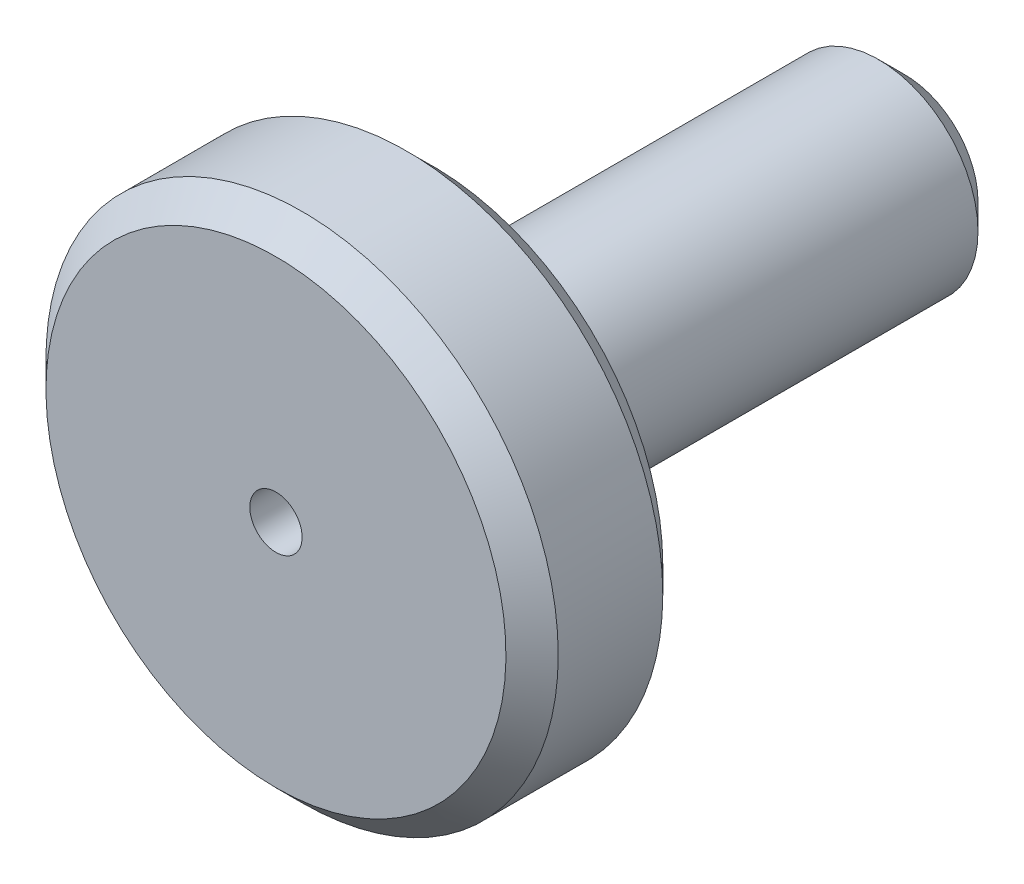
from build123d import *

# Parameters (mm, degrees)
SKETCH1_R           = 4.9
SKETCH1_R_2         = 1.9
BOSS_EXTRUDE1_DEPTH = 3
SKETCH1_4_R         = 1.9
BOSS_EXTRUDE2_DEPTH = 9.03
FILLET1_R           = 0.5
CHAMFER1_SIZE       = 0.5
CUT_EXTRUDE1_REACH  = 14.03
SKETCH2_R           = 0.5


with BuildPart() as part:
    # Sketch1 → Boss-Extrude1 (new body)
    with BuildSketch(Plane.XY):
        with Locations((-1.7071e-05, 52.925001209)):
            Circle(SKETCH1_R)
        with Locations((-1.7071e-05, 52.925001209)):
            Circle(SKETCH1_R_2, mode=Mode.SUBTRACT)
        with Locations((-1.7071e-05, 52.925001209)):
            Circle(SKETCH1_R_2)
    extrude(amount=BOSS_EXTRUDE1_DEPTH)

    # Sketch1_4 → Boss-Extrude2 (add)
    with BuildSketch(Plane.XY):
        with Locations((-1.7071e-05, 52.925001209)):
            Circle(SKETCH1_4_R)
    extrude(amount=-BOSS_EXTRUDE2_DEPTH)

    # Fillet1
    fillet1_edges = [part.edges().sort_by_distance(p)[0] for p in [
        (-1.900017071, 52.925001209, 0),
    ]]
    fillet(fillet1_edges, radius=FILLET1_R)

    # Chamfer1
    chamfer1_edges = [part.edges().sort_by_distance(p)[0] for p in [
        (-4.900017071, 52.925001209, 3),
        (-1.900017071, 52.925001209, -9.03),
        (-4.900017071, 52.925001209, 0),
    ]]
    chamfer(chamfer1_edges, length=CHAMFER1_SIZE)

    # Sketch2 → Cut-Extrude1 (cut, up to next)
    with BuildSketch(Plane.XY.offset(3), mode=Mode.PRIVATE) as cut_extrude1_sk1:
        with Locations((-1.7071e-05, 52.925001209)):
            Circle(SKETCH2_R)
    cut_extrude1_tool1 = extrude(cut_extrude1_sk1.sketch, amount=-CUT_EXTRUDE1_REACH, mode=Mode.PRIVATE) & part.part
    add(cut_extrude1_tool1.solids().sort_by_distance((-1.7e-05, 52.925001, 3))[0], mode=Mode.SUBTRACT)


solid = part.part
